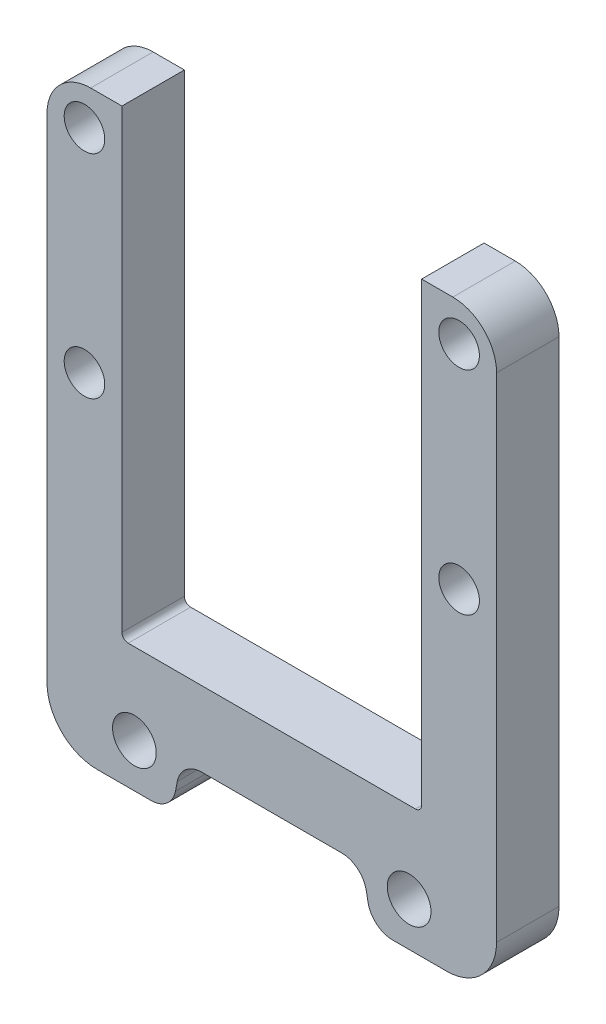
from build123d import *

# Parameters (mm, degrees)
ESQUISSE1_R        = 3.25
ESQUISSE1_R_2      = 3.5
BOSS_EXTRU_1_DEPTH = 10
CONG_1_R           = 4
CONG_2_R           = 8
CONG_3_R           = 7
CONG_4_R           = 1


with BuildPart() as part:
    # Esquisse1 → Boss.-Extru.1 (new body)
    with BuildSketch(Plane.XY):
        Polygon((24, 110), (24, 36), (0, 36), (0, 24), (14.5, 24), (16.055042473, 16), (36, 16), (36, 110), align=None)
        with Locations((30, 104)):
            Circle(ESQUISSE1_R, mode=Mode.SUBTRACT)
        with Locations((22, 23)):
            Circle(ESQUISSE1_R_2, mode=Mode.SUBTRACT)
        with Locations((30, 70)):
            Circle(ESQUISSE1_R, mode=Mode.SUBTRACT)
    boss_extru_1 = extrude(amount=BOSS_EXTRU_1_DEPTH)

    # Symétrie2: Boss.-Extru.1 across plane
    add(boss_extru_1.mirror(Plane(origin=(0, 36, 10), x_dir=(0, 0, 1), z_dir=(1, 0, 0))))

    # Congé1
    cong_1_edges = [part.edges().sort_by_distance(p)[0] for p in [
        (16.055042473, 16, 5),
        (14.5, 24, 5),
        (-14.5, 24, 5),
        (-16.055042473, 16, 5),
    ]]
    fillet(cong_1_edges, radius=CONG_1_R)

    # Congé2
    cong_2_edges = [part.edges().sort_by_distance(p)[0] for p in [
        (36, 16, 5),
        (-36, 16, 5),
    ]]
    fillet(cong_2_edges, radius=CONG_2_R)

    # Congé3
    cong_3_edges = [part.edges().sort_by_distance(p)[0] for p in [
        (36, 110, 5),
        (-36, 110, 5),
    ]]
    fillet(cong_3_edges, radius=CONG_3_R)

    # Congé4
    cong_4_edges = [part.edges().sort_by_distance(p)[0] for p in [
        (24, 36, 5),
        (-24, 36, 5),
    ]]
    fillet(cong_4_edges, radius=CONG_4_R)


solid = part.part
